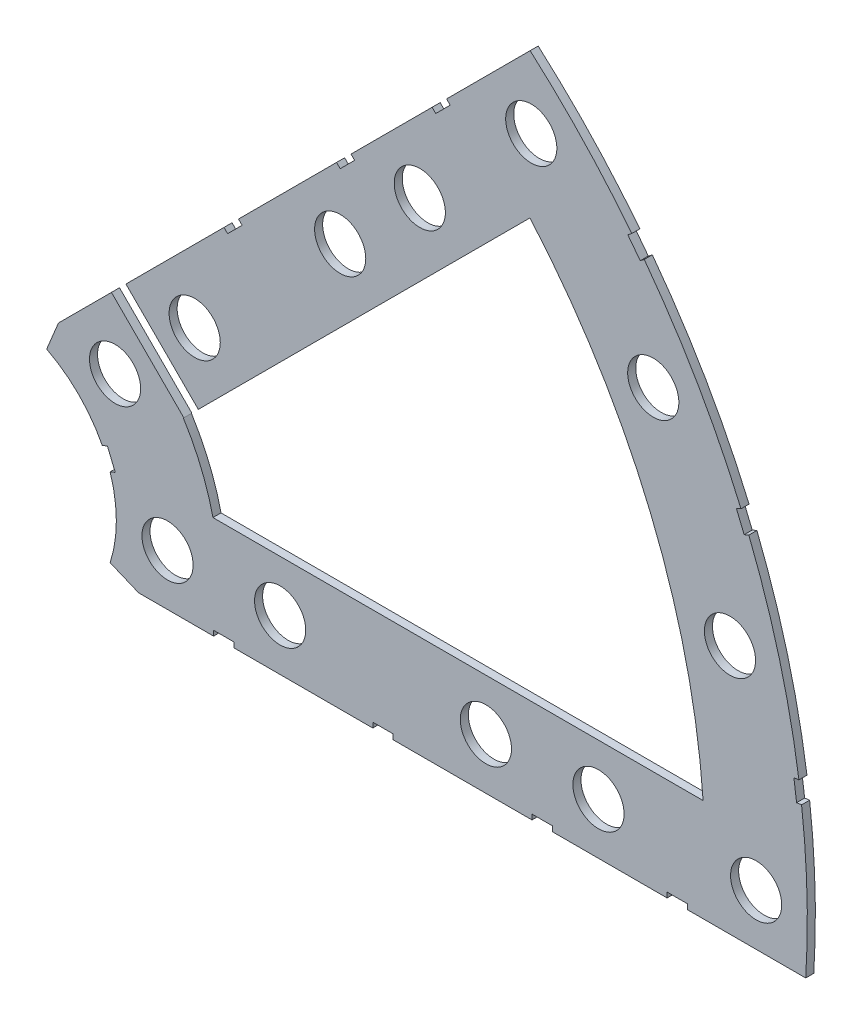
from build123d import *

# Parameters (mm, degrees)
BOSS_EXTRUDE1_DEPTH = 1
SKETCH2_R           = 3.175
CUT_EXTRUDE1_DEPTH  = 2
SKETCH3_W           = 2.54
SKETCH3_H           = 0.635
CUT_EXTRUDE2_DEPTH  = 2


with BuildPart() as part:
    # Sketch1 → Boss-Extrude1 (new body)
    with BuildSketch(Plane.XY):
        with BuildLine():
            Line((67.21146711, 76.191723231), (8.696654013, 17.676910134))
            Line((8.696654013, 17.676910134), (7.228954972, 14.133571205))
            ThreePointArc((7.228954972, 14.133571205), (14.666587579, 6.075099489), (15.105587123, -4.88230096))
            Line((15.105587123, -4.88230096), (18.648926052, -6.35))
            Line((18.648926052, -6.35), (101.401368334, -6.35))
            ThreePointArc((101.401368334, -6.35), (93.866160503, 38.880636728), (67.21146711, 76.191723231))
        make_face()
        with BuildLine():
            Line((88.672924278, 6.35), (27.86051193, 6.35))
            ThreePointArc((27.86051193, 6.35), (26.399857642, 10.93517908), (24.190484974, 15.210228852))
            Line((24.190484974, 15.210228852), (67.191354125, 58.211098004))
            ThreePointArc((67.191354125, 58.211098004), (82.13289044, 34.020557137), (88.672924278, 6.35))
        make_face(mode=Mode.SUBTRACT)
    extrude(amount=BOSS_EXTRUDE1_DEPTH)

    # Sketch2 → Cut-Extrude1 (cut, through all)
    with BuildSketch(Plane.XY.offset(1)):
        with Locations((22.225, 0)):
            Circle(SKETCH2_R)
        with Locations((36.195, 0)):
            Circle(SKETCH2_R)
        with Locations((61.722, 0)):
            Circle(SKETCH2_R)
        with Locations((75.692, 0)):
            Circle(SKETCH2_R)
        with Locations((95.25, 0)):
            Circle(SKETCH2_R)
        with Locations((15.715448212, 15.715448212)):
            Circle(SKETCH2_R)
        with Locations((25.593729945, 25.593729945)):
            Circle(SKETCH2_R)
        with Locations((43.644044748, 43.644044748)):
            Circle(SKETCH2_R)
        with Locations((53.522326482, 53.522326482)):
            Circle(SKETCH2_R)
        with Locations((92.004434954, 24.652514046)):
            Circle(SKETCH2_R)
        with Locations((82.48891971, 47.625)):
            Circle(SKETCH2_R)
        with Locations((67.351920908, 67.351920908)):
            Circle(SKETCH2_R)
    extrude(amount=-CUT_EXTRUDE1_DEPTH, mode=Mode.SUBTRACT)

    # Sketch3 → Cut-Extrude2 (cut, through all)
    with BuildSketch(Plane.XY.offset(1)):
        Polygon((25.144717139, 14.368409794), (14.368409794, 25.144717139), (16.164461018, 26.940768363), (26.940768363, 16.164461018), align=None)
        Polygon((44.991083167, 53.971339288), (43.195031942, 52.175288063), (43.644044748, 51.726275257), (45.440095973, 53.522326482), align=None)
        with Locations((29.21, -6.0325)):
            Rectangle(SKETCH3_W, SKETCH3_H)
        with Locations((68.707, -6.0325)):
            Rectangle(SKETCH3_W, SKETCH3_H)
        Polygon((29.230733674, 38.210989795), (31.026784898, 40.007041019), (31.475797704, 39.558028213), (29.67974648, 37.761976989), align=None)
        Polygon((56.845021246, 65.825277367), (55.048970022, 64.029226143), (55.497982828, 63.580213337), (57.294034052, 65.376264561), align=None)
        with Locations((48.9585, -6.0325)):
            Rectangle(SKETCH3_W, SKETCH3_H)
        with Locations((85.471, -6.0325)):
            Rectangle(SKETCH3_W, SKETCH3_H)
        Polygon((99.935462164, 14.437711971), (100.266998693, 11.919442024), (101.526133667, 12.085210288), (101.194597138, 14.603480236), align=None)
        Polygon((93.765504959, 37.464305742), (94.938831965, 37.950313702), (93.966816047, 40.296967714), (92.793489041, 39.810959755), align=None)
        Polygon((79.327792988, 62.471156422), (80.874047017, 60.456038938), (81.88160576, 61.229165953), (80.33535173, 63.244283437), align=None)
        Polygon((13.593916116, 7.005422516), (14.565932035, 4.658768503), (15.739259041, 5.144776462), (14.767243123, 7.491430475), align=None)
    extrude(amount=-CUT_EXTRUDE2_DEPTH, mode=Mode.SUBTRACT)


solid = part.part
